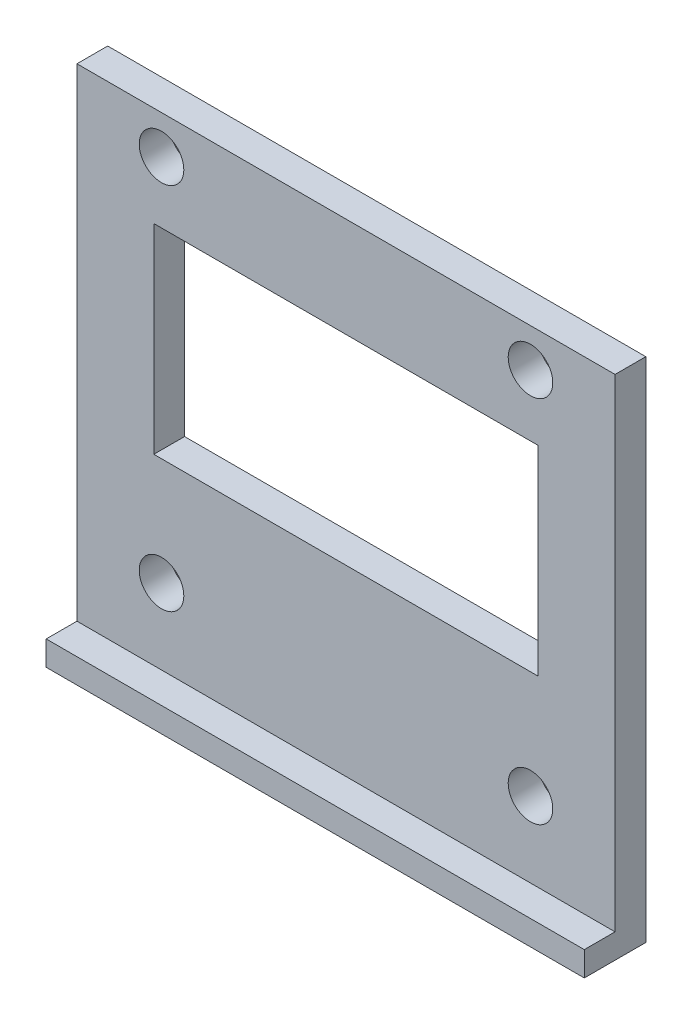
from build123d import *

# Parameters (mm, degrees)
SKETCH1_W           = 29
SKETCH1_H           = 28
SKETCH1_W_2         = 25
SKETCH1_H_2         = 13
BOSS_EXTRUDE1_DEPTH = 2
SKETCH2_R           = 1.45
CUT_EXTRUDE1_DEPTH  = 3
BOSS_EXTRUDE2_DEPTH = 29
SKETCH5_W           = 29
SKETCH5_H           = 2
BOSS_EXTRUDE3_DEPTH = 1
SKETCH6_W           = 2
SKETCH6_H           = 33
SKETCH6_H_2         = 1.6
BOSS_EXTRUDE4_DEPTH = 3
SKETCH7_W           = 2
SKETCH7_H           = 33
SKETCH7_H_2         = 1.6
BOSS_EXTRUDE5_DEPTH = 3


with BuildPart() as part:
    # Sketch1 → Boss-Extrude1 (new body)
    with BuildSketch(Plane.XY):
        with Locations((0, -2)):
            Rectangle(SKETCH1_W, SKETCH1_H)
        Rectangle(SKETCH1_W_2, SKETCH1_H_2, mode=Mode.SUBTRACT)
    extrude(amount=BOSS_EXTRUDE1_DEPTH)

    # Sketch2 → Cut-Extrude1 (cut, through all)
    with BuildSketch(Plane.XY.offset(2)):
        with Locations((-12, 10.5)):
            Circle(SKETCH2_R)
        with Locations((-12, -13.5)):
            Circle(SKETCH2_R)
        with Locations((12, -13.5)):
            Circle(SKETCH2_R)
        with Locations((12, 10.5)):
            Circle(SKETCH2_R)
    extrude(amount=-CUT_EXTRUDE1_DEPTH, mode=Mode.SUBTRACT)

    # Sketch3 → Boss-Extrude2 (add, through all)
    with BuildSketch(Plane(origin=(14.5, 0, 0), x_dir=(0, 0, -1), z_dir=(1, 0, 0))):
        Polygon((-4, -20), (0, -20), (0, -18.4), (0, -16), (-2, -16), (-2, -18.4), (-4, -18.4), align=None)
    extrude(amount=-BOSS_EXTRUDE2_DEPTH)

    # Sketch5 → Boss-Extrude3 (add)
    with BuildSketch(Plane(origin=(0, 12, 0), x_dir=(1, 0, 0), z_dir=(0, 1, 0))):
        with Locations((0, -1)):
            Rectangle(SKETCH5_W, SKETCH5_H)
    extrude(amount=BOSS_EXTRUDE3_DEPTH)

    # Sketch6 → Boss-Extrude4 (add)
    with BuildSketch(Plane.ZY.offset(14.5)):
        with Locations((1, -3.5)):
            Rectangle(SKETCH6_W, SKETCH6_H)
        with Locations((3, -19.2)):
            Rectangle(SKETCH6_W, SKETCH6_H_2)
    extrude(amount=BOSS_EXTRUDE4_DEPTH)

    # Sketch7 → Boss-Extrude5 (add)
    with BuildSketch(Plane(origin=(14.5, 0, 0), x_dir=(0, 0, -1), z_dir=(1, 0, 0))):
        with Locations((-1, -3.5)):
            Rectangle(SKETCH7_W, SKETCH7_H)
        with Locations((-3, -19.2)):
            Rectangle(SKETCH7_W, SKETCH7_H_2)
    extrude(amount=BOSS_EXTRUDE5_DEPTH)


solid = part.part
